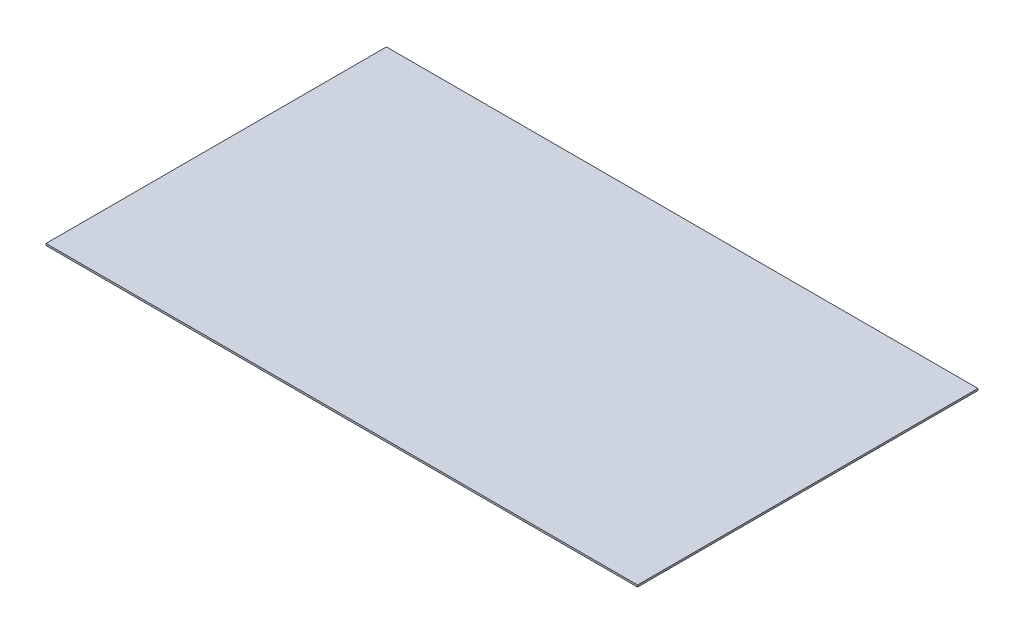
from build123d import *

# Parameters (mm, degrees)
SKETCH1_W           = 3210.766966772
SKETCH1_H           = 1847.656320878
BOSS_EXTRUDE1_DEPTH = 10


with BuildPart() as part:
    # Sketch1 → Boss-Extrude1 (new body)
    with BuildSketch(Plane(origin=(0, 0, 0), x_dir=(1, 0, 0), z_dir=(0, 1, 0))):
        with Locations((-1391.529574808, 832.257736819)):
            Rectangle(SKETCH1_W, SKETCH1_H)
    extrude(amount=BOSS_EXTRUDE1_DEPTH)


solid = part.part
